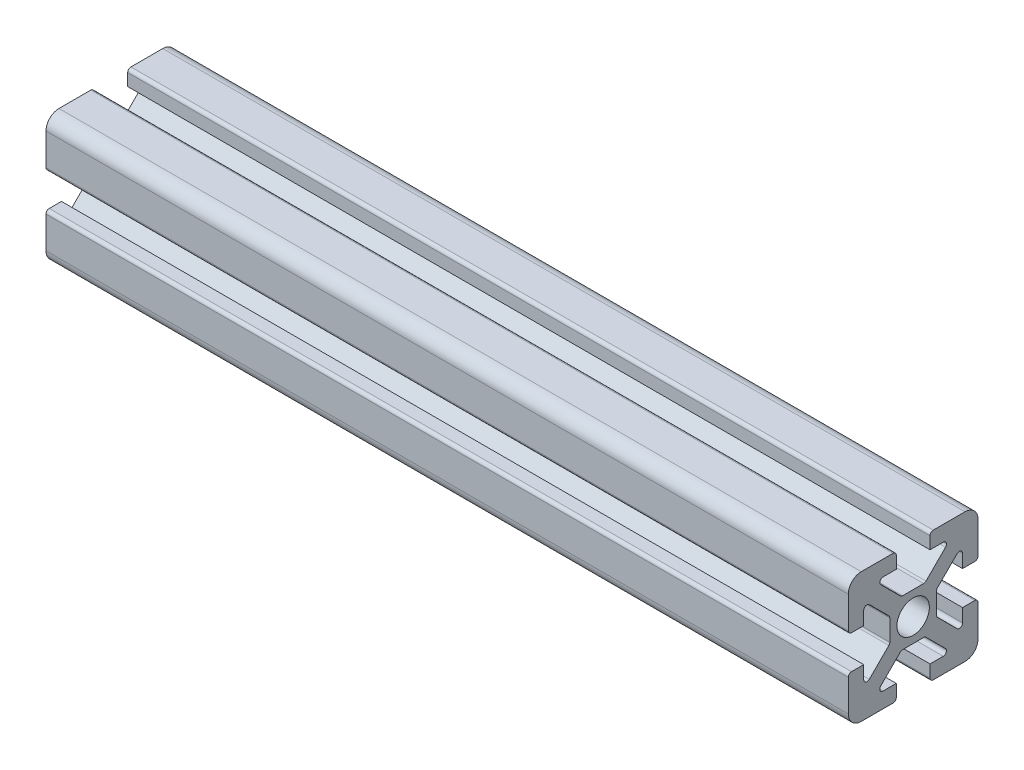
from build123d import *

# Parameters (mm, degrees)
SKETCH1_R           = 2.5
BOSS_EXTRUDE1_DEPTH = 61.849
FILLET1_R           = 2
FILLET2_R           = 0.5


with BuildPart() as part:
    # Sketch1 → Boss-Extrude1 (new body, symmetric)
    with BuildSketch(Plane(origin=(0, 0, 0), x_dir=(0, 0, -1), z_dir=(1, 0, 0))):
        Polygon((-2.6, 10), (-2.6, 7.617766953), (-5.85, 7.617766953), (-1.832233047, 3.6), (1.832233047, 3.6), (5.85, 7.617766953), (2.6, 7.617766953), (2.6, 10), (10, 10), (10, 2.6), (7.617766953, 2.6), (7.617766953, 5.85), (3.6, 1.832233047), (3.6, -1.832233047), (7.617766953, -5.85), (7.617766953, -2.6), (10, -2.6), (10, -10), (2.6, -10), (2.6, -7.617766953), (5.85, -7.617766953), (1.832233047, -3.6), (-1.832233047, -3.6), (-5.85, -7.617766953), (-2.6, -7.617766953), (-2.6, -10), (-10, -10), (-10, -2.6), (-7.617766953, -2.6), (-7.617766953, -5.85), (-3.6, -1.832233047), (-3.6, 1.832233047), (-7.617766953, 5.85), (-7.617766953, 2.6), (-10, 2.6), (-10, 10), align=None)
        Circle(SKETCH1_R, mode=Mode.SUBTRACT)
    extrude(amount=BOSS_EXTRUDE1_DEPTH, both=True)

    # Fillet1
    fillet1_edges = [part.edges().sort_by_distance(p)[0] for p in [
        (0, 10, 10),
        (0, 10, -10),
        (0, -10, -10),
        (0, -10, 10),
    ]]
    fillet(fillet1_edges, radius=FILLET1_R)

    # Fillet2
    fillet2_edges = [part.edges().sort_by_distance(p)[0] for p in [
        (0, 10, 2.6),
        (0, 7.617766953, 5.85),
        (0, 3.6, 1.832233047),
        (0, 3.6, -1.832233047),
        (0, 7.617766953, -5.85),
        (0, 10, -2.6),
        (0, 2.6, -10),
        (0, 5.85, -7.617766953),
        (0, 1.832233047, -3.6),
        (0, -1.832233047, -3.6),
        (0, -5.85, -7.617766953),
        (0, -2.6, -10),
        (0, -10, -2.6),
        (0, -7.617766953, -5.85),
        (0, -3.6, -1.832233047),
        (0, -3.6, 1.832233047),
        (0, -7.617766953, 5.85),
        (0, -10, 2.6),
        (0, -2.6, 10),
        (0, -5.85, 7.617766953),
        (0, -1.832233047, 3.6),
        (0, 1.832233047, 3.6),
        (0, 5.85, 7.617766953),
        (0, 2.6, 10),
    ]]
    fillet(fillet2_edges, radius=FILLET2_R)


solid = part.part
